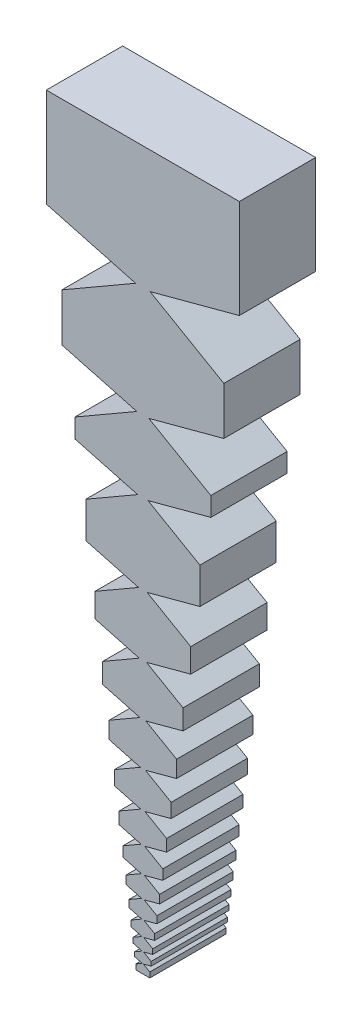
from build123d import *

# Parameters (mm, degrees)
BOSS_EXTRUDE1_DEPTH = 10


with BuildPart() as part:
    # spiral_flat → Boss-Extrude1 (new body)
    with BuildSketch(Plane.XY):
        with BuildLine():
            Line((0, 93.978977978), (-12.645458185, 93.978977978))
            Line((-12.645458185, 93.978977978), (-12.645458185, 81.037355698))
            Line((-12.645458185, 81.037355698), (-0.948409364, 77.903140912))
            Line((-0.948409364, 77.903140912), (-10.613540319, 72.322974954))
            Line((-10.613540319, 72.322974954), (-10.613540319, 66.071506497))
            Line((-10.613540319, 66.071506497), (-0.785032027, 63.437965637))
            Line((-0.785032027, 63.437965637), (-8.90811835, 58.748099562))
            Line((-8.90811835, 58.748099562), (-8.90811835, 56.263194352))
            Line((-8.90811835, 56.263194352), (-0.679092373, 54.058233487))
            Line((-0.679092373, 54.058233487), (-7.476729738, 50.133615724))
            Line((-7.476729738, 50.133615724), (-7.476729738, 45.433932588))
            Line((-7.476729738, 45.433932588), (-0.56075473, 43.58080267))
            Line((-0.56075473, 43.58080267), (-6.275341816, 40.281484278))
            Line((-6.275341816, 40.281484278), (-6.275341816, 37.158488644))
            Line((-6.275341816, 37.158488644), (-0.470650636, 35.603126331))
            Line((-0.470650636, 35.603126331), (-5.266997241, 32.833954327))
            Line((-5.266997241, 32.833954327), (-5.266997241, 30.212772905))
            Line((-5.266997241, 30.212772905), (-0.395024793, 28.907331822))
            Line((-0.395024793, 28.907331822), (-4.420677113, 26.583120371))
            Line((-4.420677113, 26.583120371), (-4.420677113, 24.383079269))
            Line((-4.420677113, 24.383079269), (-0.331702205, 23.287441744))
            Line((-0.331702205, 23.287441744), (-3.710346757, 21.336780402))
            Line((-3.710346757, 21.336780402), (-3.710346757, 19.490083441))
            Line((-3.710346757, 19.490083441), (-0.278697859, 18.57057589))
            Line((-0.278697859, 18.57057589), (-3.114154847, 16.933524034))
            Line((-3.114154847, 16.933524034), (-3.114154847, 15.383475192))
            Line((-3.114154847, 15.383475192), (-0.233600822, 14.611633067))
            Line((-0.233600822, 14.611633067), (-2.613761206, 13.237446829))
            Line((-2.613761206, 13.237446829), (-2.613761206, 11.936656031))
            Line((-2.613761206, 11.936656031), (-0.19603209, 11.288827467))
            Line((-0.19603209, 11.288827467), (-2.19377262, 10.135431435))
            Line((-2.19377262, 10.135431435), (-2.19377262, 9.043614273))
            Line((-2.19377262, 9.043614273), (-0.164761066, 8.499942265))
            Line((-0.164761066, 8.499942265), (-1.841269317, 7.532009775))
            Line((-1.841269317, 7.532009775), (-1.841269317, 6.615509703))
            Line((-1.841269317, 6.615509703), (-0.138243102, 6.159185204))
            Line((-0.138243102, 6.159185204), (-1.545407517, 5.346758451))
            Line((-1.545407517, 5.346758451), (-1.545407517, 4.577583331))
            Line((-1.545407517, 4.577583331), (-0.115905564, 4.194549437))
            Line((-0.115905564, 4.194549437), (-1.297085859, 3.512594676))
            Line((-1.297085859, 3.512594676), (-1.297085859, 2.867070252))
            Line((-1.297085859, 2.867070252), (-0.097336711, 2.545598437))
            Line((-0.097336711, 2.545598437), (-1.088665421, 1.973254539))
            Line((-1.088665421, 1.973254539), (-1.088665421, 1.431435829))
            Line((-1.088665421, 1.431435829), (-0.081649907, 1.161606835))
            Line((-0.081649907, 1.161606835), (-0.913734731, 0.681202438))
            Line((-0.913734731, 0.681202438), (-0.913734731, 0))
            Line((-0.913734731, 0), (0, 0))
            add(Edge.make_bspline(
                [(0, 0), (0, 0.387202278), (0, 1.235735091), (0, 2.633918237), (0, 4.299777693), (0, 6.284558969), (0, 8.649318312), (0, 11.466800933), (0, 14.823678808), (0, 18.8232169), (0, 23.588449819), (0, 29.265966632), (0, 36.030420274), (0, 44.414054162), (0, 53.692333931), (0, 65.133113345), (0, 78.440028176), (0, 88.620365623), (0, 93.978977978)],
                knots=[0, 0, 0, 0, 0.012360284, 0.027086892, 0.044632848, 0.065537904, 0.090445145, 0.120120773, 0.155477676, 0.19760351, 0.247794158, 0.307593596, 0.378841387, 0.463729268, 0.575216231, 0.675022936, 0.828942202, 1, 1, 1, 1], degree=3))
        make_face()
        with BuildLine():
            Line((12.645458185, 93.978977978), (0, 93.978977978))
            add(Edge.make_bspline(
                [(0, 0), (0, 0.387202278), (0, 1.235735091), (0, 2.633918237), (0, 4.299777693), (0, 6.284558969), (0, 8.649318312), (0, 11.466800933), (0, 14.823678808), (0, 18.8232169), (0, 23.588449819), (0, 29.265966632), (0, 36.030420274), (0, 44.414054162), (0, 53.692333931), (0, 65.133113345), (0, 78.440028176), (0, 88.620365623), (0, 93.978977978)],
                knots=[0, 0, 0, 0, 0.012360284, 0.027086892, 0.044632848, 0.065537904, 0.090445145, 0.120120773, 0.155477676, 0.19760351, 0.247794158, 0.307593596, 0.378841387, 0.463729268, 0.575216231, 0.675022936, 0.828942202, 1, 1, 1, 1], degree=3))
            Line((0, 0), (0.913734731, 0))
            Line((0.913734731, 0), (0.913734731, 0.681202438))
            Line((0.913734731, 0.681202438), (0.081649907, 1.161606835))
            Line((0.081649907, 1.161606835), (1.088665421, 1.431435829))
            Line((1.088665421, 1.431435829), (1.088665421, 1.973254539))
            Line((1.088665421, 1.973254539), (0.097336711, 2.545598437))
            Line((0.097336711, 2.545598437), (1.297085859, 2.867070252))
            Line((1.297085859, 2.867070252), (1.297085859, 3.512594676))
            Line((1.297085859, 3.512594676), (0.115905564, 4.194549437))
            Line((0.115905564, 4.194549437), (1.545407517, 4.577583331))
            Line((1.545407517, 4.577583331), (1.545407517, 5.346758451))
            Line((1.545407517, 5.346758451), (0.138243102, 6.159185204))
            Line((0.138243102, 6.159185204), (1.841269317, 6.615509703))
            Line((1.841269317, 6.615509703), (1.841269317, 7.532009775))
            Line((1.841269317, 7.532009775), (0.164761066, 8.499942265))
            Line((0.164761066, 8.499942265), (2.19377262, 9.043614273))
            Line((2.19377262, 9.043614273), (2.19377262, 10.135431435))
            Line((2.19377262, 10.135431435), (0.19603209, 11.288827467))
            Line((0.19603209, 11.288827467), (2.613761206, 11.936656031))
            Line((2.613761206, 11.936656031), (2.613761206, 13.237446829))
            Line((2.613761206, 13.237446829), (0.233600822, 14.611633067))
            Line((0.233600822, 14.611633067), (3.114154847, 15.383475192))
            Line((3.114154847, 15.383475192), (3.114154847, 16.933524034))
            Line((3.114154847, 16.933524034), (0.278697859, 18.57057589))
            Line((0.278697859, 18.57057589), (3.710346757, 19.490083441))
            Line((3.710346757, 19.490083441), (3.710346757, 21.336780402))
            Line((3.710346757, 21.336780402), (0.331702205, 23.287441744))
            Line((0.331702205, 23.287441744), (4.420677113, 24.383079269))
            Line((4.420677113, 24.383079269), (4.420677113, 26.583120371))
            Line((4.420677113, 26.583120371), (0.395024793, 28.907331822))
            Line((0.395024793, 28.907331822), (5.266997241, 30.212772905))
            Line((5.266997241, 30.212772905), (5.266997241, 32.833954327))
            Line((5.266997241, 32.833954327), (0.470650636, 35.603126331))
            Line((0.470650636, 35.603126331), (6.275341816, 37.158488644))
            Line((6.275341816, 37.158488644), (6.275341816, 40.281484278))
            Line((6.275341816, 40.281484278), (0.56075473, 43.58080267))
            Line((0.56075473, 43.58080267), (7.476729738, 45.433932588))
            Line((7.476729738, 45.433932588), (7.476729738, 50.133615724))
            Line((7.476729738, 50.133615724), (0.679092373, 54.058233487))
            Line((0.679092373, 54.058233487), (8.90811835, 56.263194352))
            Line((8.90811835, 56.263194352), (8.90811835, 58.748099562))
            Line((8.90811835, 58.748099562), (0.785032027, 63.437965637))
            Line((0.785032027, 63.437965637), (10.613540319, 66.071506497))
            Line((10.613540319, 66.071506497), (10.613540319, 72.322974954))
            Line((10.613540319, 72.322974954), (0.948409364, 77.903140912))
            Line((0.948409364, 77.903140912), (12.645458185, 81.037355698))
            Line((12.645458185, 81.037355698), (12.645458185, 93.978977978))
        make_face()
    extrude(amount=BOSS_EXTRUDE1_DEPTH)


solid = part.part
